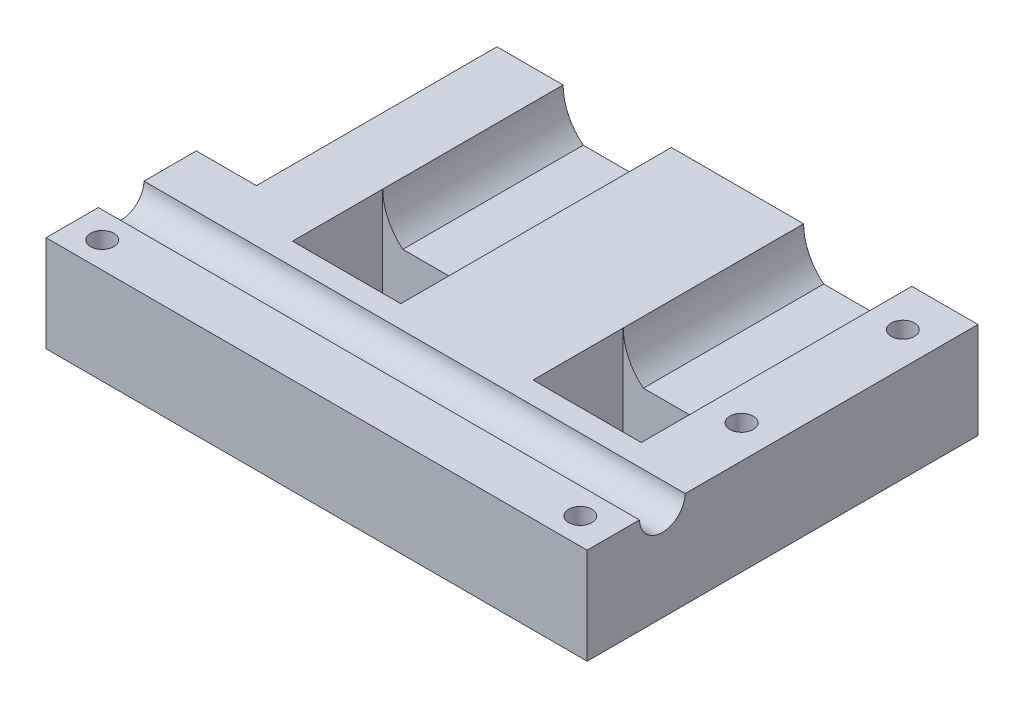
from build123d import *

# Parameters (mm, degrees)
BOSS_EXTRUDE1_DEPTH  = 38.1
SKETCH7_W            = 101.6
SKETCH7_H            = 20.32
BOSS_EXTRUDE2_DEPTH  = 44.45
BOSS_EXTRUDE9_DEPTH  = 12.7
SKETCH8_W            = 22.86
SKETCH8_H            = 19.05
CUT_EXTRUDE1_DEPTH   = 20.32
CUT_EXTRUDE2_START   = -101.6
SKETCH9_R            = 4.826
CUT_EXTRUDE2_DEPTH   = 114.3
LPATTERN1_COUNT      = 3
LPATTERN1_PITCH      = 34.067332164
LPATTERN1_COUNT_DIR2 = 2
LPATTERN1_PITCH_DIR2 = 100.965


with BuildPart() as part:
    # Sketch1 → Boss-Extrude1 (new body)
    with BuildSketch(Plane.XY):
        with BuildLine():
            Line((-50.8, 0), (50.8, 0))
            Line((50.8, 0), (50.8, 20.32))
            Line((50.8, 20.32), (36.83, 20.32))
            ThreePointArc((36.83, 20.32), (35.714076836, 15.394076836), (32.584204897, 11.43))
            Line((32.584204897, 11.43), (18.215795103, 11.43))
            ThreePointArc((18.215795103, 11.43), (15.085923164, 15.394076836), (13.97, 20.32))
            Line((13.97, 20.32), (-13.97, 20.32))
            ThreePointArc((-13.97, 20.32), (-15.085923164, 15.394076836), (-18.215795103, 11.43))
            Line((-18.215795103, 11.43), (-32.584204897, 11.43))
            ThreePointArc((-32.584204897, 11.43), (-35.714076836, 15.394076836), (-36.83, 20.32))
            Line((-36.83, 20.32), (-50.8, 20.32))
            Line((-50.8, 20.32), (-50.8, 0))
        make_face()
    extrude(amount=BOSS_EXTRUDE1_DEPTH)

    # Sketch7 → Boss-Extrude2 (add)
    with BuildSketch(Plane.XY.offset(38.1)):
        with Locations((0, 10.16)):
            Rectangle(SKETCH7_W, SKETCH7_H)
    extrude(amount=BOSS_EXTRUDE2_DEPTH)

    # Sketch21 → Boss-Extrude9 (add)
    with BuildSketch(Plane.ZY.offset(50.8)):
        Polygon((0, 7.112), (0, 0), (68.41445042, 0), (82.55, 0), (82.55, 7.153488119), (82.55, 20.32), (50.8, 20.32), (50.8, 7.112), align=None)
    extrude(amount=BOSS_EXTRUDE9_DEPTH)

    # Sketch8 → Cut-Extrude1 (cut)
    with BuildSketch(Plane(origin=(0, 20.32, 0), x_dir=(1, 0, 0), z_dir=(0, 1, 0))):
        with Locations((-25.4, -47.625)):
            Rectangle(SKETCH8_W, SKETCH8_H)
        with Locations((25.4, -47.625)):
            Rectangle(SKETCH8_W, SKETCH8_H)
    extrude(amount=-CUT_EXTRUDE1_DEPTH, mode=Mode.SUBTRACT)

    # Sketch5 → #10 (0.1935) Diameter Hole1 (revolve, cut)
    with BuildSketch(Plane(origin=(-57.15, 20.32, 8.89), x_dir=(0, 0, 1), z_dir=(1, 0, 0))):
        Polygon((0, 0), (0, 25.4), (2.45745, 23.923415072), (2.45745, 0), align=None)
    f_10_0_1935_diameter_hole1 = revolve(axis=Axis((-57.15, 26.67, 8.89), (0, -1, 0)), mode=Mode.SUBTRACT)

    # Sketch9 → Cut-Extrude2 (cut)
    with BuildSketch(Plane.ZY.offset(50.8).offset(CUT_EXTRUDE2_START)):
        with Locations((66.675, 20.447)):
            Circle(SKETCH9_R)
    extrude(amount=CUT_EXTRUDE2_DEPTH, mode=Mode.SUBTRACT)

    # LPattern1: 10 _0.1935_ Diameter Hole1 3 × 2
    with Locations(*[(j * LPATTERN1_PITCH_DIR2, 0, i * LPATTERN1_PITCH) for i in range(LPATTERN1_COUNT) for j in range(LPATTERN1_COUNT_DIR2) if (i, j) != (0, 0)]):
        add(f_10_0_1935_diameter_hole1, mode=Mode.SUBTRACT)


solid = part.part
